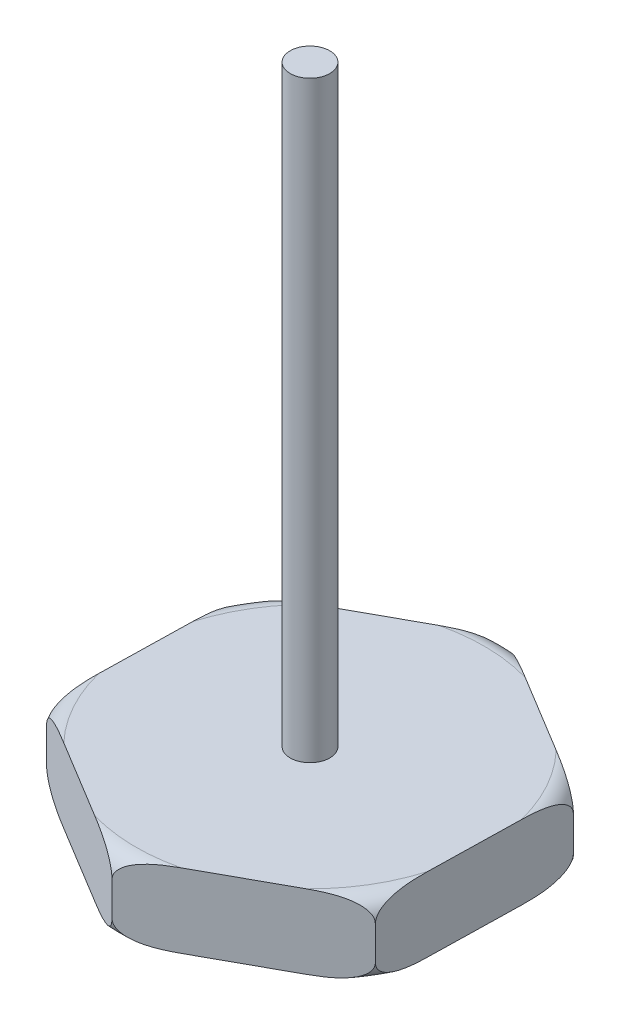
from build123d import *

# Parameters (mm, degrees)
BOSS_EXTRUDE1_DEPTH = 1.875
SKETCH2_R           = 1
BOSS_EXTRUDE2_DEPTH = 30


with BuildPart() as part:
    # Sketch1 → Boss-Extrude1 (new body, symmetric)
    with BuildSketch(Plane(origin=(0, 0, 0), x_dir=(1, 0, 0), z_dir=(0, 1, 0))):
        Polygon((8.603650459, 4.727949427), (0.207300918, 9.814954576), (-8.396349541, 5.087005149), (-8.603650459, -4.727949427), (-0.207300918, -9.814954576), (8.396349541, -5.087005149), align=None)
    extrude(amount=BOSS_EXTRUDE1_DEPTH, both=True)

    # Sketch2 → Boss-Extrude2 (add)
    with BuildSketch(Plane(origin=(0, 1.875, 0), x_dir=(1, 0, 0), z_dir=(0, 1, 0))):
        Circle(SKETCH2_R)
    extrude(amount=BOSS_EXTRUDE2_DEPTH)

    # Sketch3 → Cut-Revolve1 (revolve, cut)
    with BuildSketch(Plane(origin=(0, 0, 0), x_dir=(0, 0, -1), z_dir=(1, 0, 0))):
        with BuildLine():
            Line((-7.638983711, -1.875), (-8.814954576, -1.875))
            ThreePointArc((-8.814954576, -1.875), (-9.522061357, -1.582106781), (-9.814954576, -0.875))
            Line((-9.814954576, -0.875), (-9.814954576, -0.236690097))
            Line((-9.814954576, -0.236690097), (-12.690091337, -2.588009386))
            Line((-12.690091337, -2.588009386), (-8.538791087, -3.391496898))
            Line((-8.538791087, -3.391496898), (-7.638983711, -1.875))
        make_face()
        with BuildLine():
            Line((-9.814954576, 0.342296512), (-9.814954576, 0.875))
            ThreePointArc((-9.814954576, 0.875), (-9.522061357, 1.582106781), (-8.814954576, 1.875))
            Line((-8.814954576, 1.875), (-7.819902103, 1.875))
            Line((-7.819902103, 1.875), (-11.754866647, 3.826938138))
            Line((-11.754866647, 3.826938138), (-9.814954576, 0.342296512))
        make_face()
    revolve(axis=Axis((0, 0, 0), (0, -1, 0)), mode=Mode.SUBTRACT)


solid = part.part
